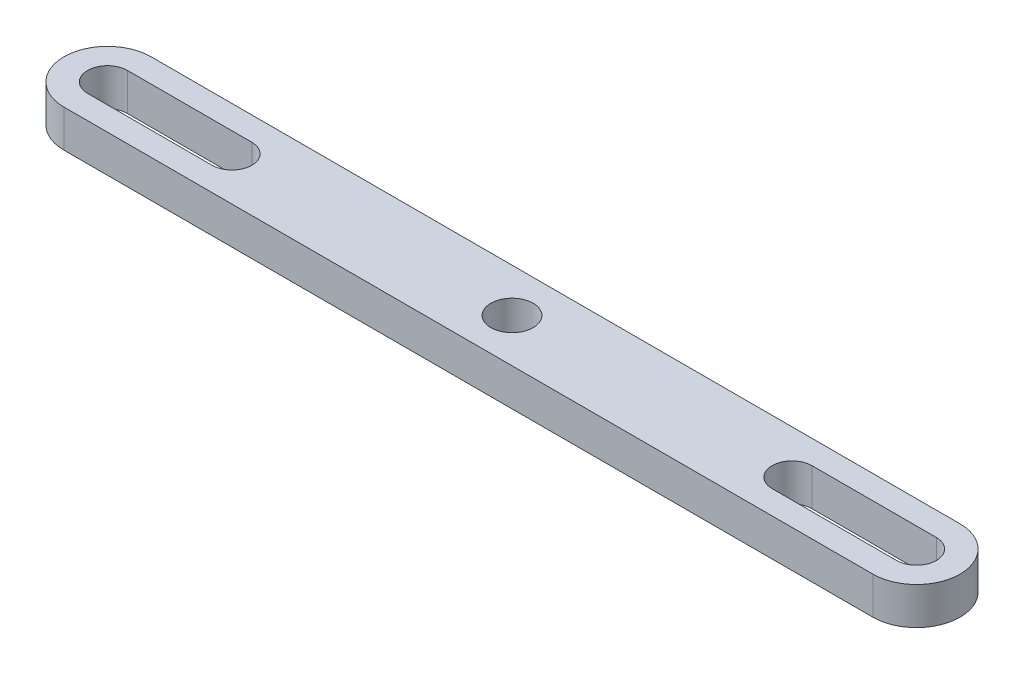
from build123d import *

# Parameters (mm, degrees)
SKETCH_1_R      = 1.7
EXTRUDE_1_DEPTH = 3


with BuildPart() as part:
    # Эскиз1 → Бобышка-Вытянуть1 (new body)
    with BuildSketch(Plane(origin=(0, 0, 0), x_dir=(1, 0, 0), z_dir=(0, 1, 0))):
        with BuildLine():
            Line((-32.5, 3.5), (32.5, 3.5))
            ThreePointArc((32.5, 3.5), (36, 0), (32.5, -3.5))
            Line((32.5, -3.5), (-32.5, -3.5))
            ThreePointArc((-32.5, -3.5), (-36, 0), (-32.5, 3.5))
        make_face()
        Circle(SKETCH_1_R, mode=Mode.SUBTRACT)
        with BuildLine():
            Line((-32.5, -1.6), (-22.5, -1.6))
            ThreePointArc((-22.5, -1.6), (-20.9, 0), (-22.5, 1.6))
            Line((-22.5, 1.6), (-32.5, 1.6))
            ThreePointArc((-32.5, 1.6), (-34.1, 0), (-32.5, -1.6))
        make_face(mode=Mode.SUBTRACT)
        with BuildLine():
            Line((22.5, 1.6), (32.5, 1.6))
            ThreePointArc((32.5, 1.6), (34.1, 0), (32.5, -1.6))
            Line((32.5, -1.6), (22.5, -1.6))
            ThreePointArc((22.5, -1.6), (20.9, 0), (22.5, 1.6))
        make_face(mode=Mode.SUBTRACT)
    extrude(amount=EXTRUDE_1_DEPTH)


solid = part.part
